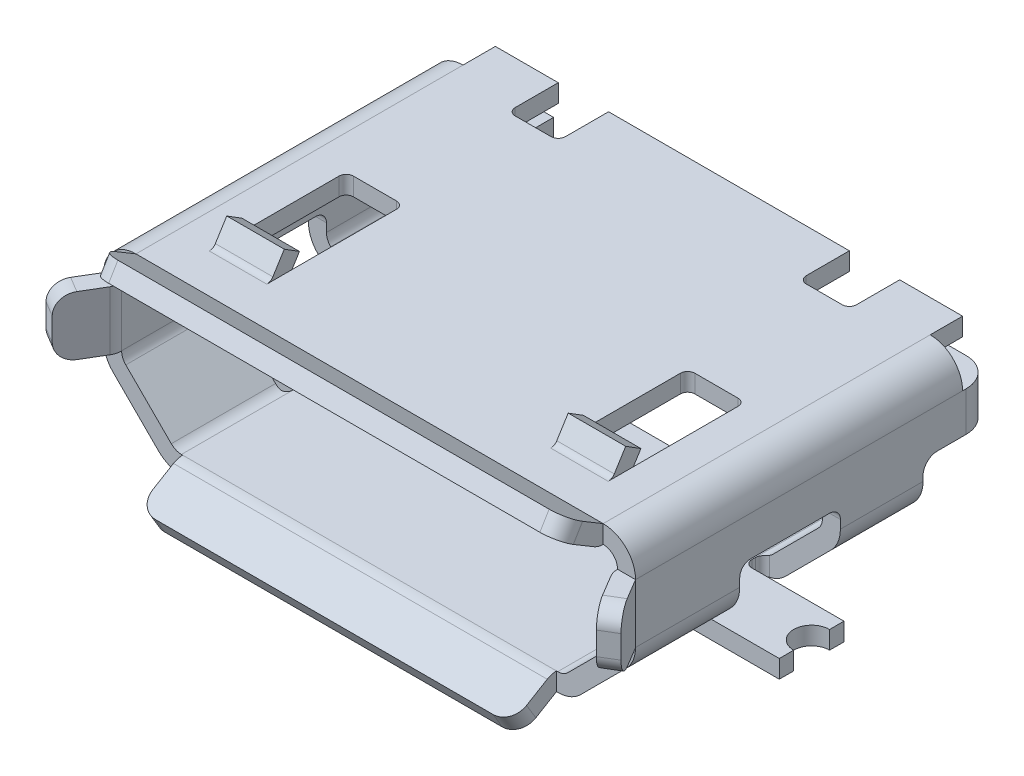
from build123d import *

# Parameters (mm, degrees)
EXTRUDE_THIN1_DEPTH     = 5
BOSS_EXTRUDE1_DEPTH     = 0.82
BOSS_EXTRUDE2_DEPTH     = 2.6
BOSS_EXTRUDE3_DEPTH     = 3.25
FILLET1_R               = 0.25
CUT_EXTRUDE1_DEPTH      = 1.1
CUT_EXTRUDE1_DEPTH_BACK = 1.55
FILLET2_R               = 0.15
BOSS_EXTRUDE4_DEPTH     = 0.25
FILLET3_R               = 0.1
CUT_EXTRUDE2_DEPTH      = 0.25
BOSS_EXTRUDE5_DEPTH     = 0.8
FILLET4_R               = 0.1
CUT_EXTRUDE3_DEPTH      = 5
CUT_EXTRUDE3_DEPTH_BACK = 5
SKETCH11_W              = 0.45
SKETCH11_H              = 0.45
CUT_EXTRUDE4_DEPTH      = 1.3
CUT_EXTRUDE4_DEPTH_BACK = 3.65
CUT_EXTRUDE5_DEPTH      = 0.8
FILLET5_R               = 0.1
CUT_EXTRUDE6_DEPTH      = 0.8
BOSS_EXTRUDE6_DEPTH     = 0.55


with BuildPart() as part:
    # Sketch1 → Extrude-Thin1 (new body)
    with BuildSketch(Plane.XY):
        with BuildLine():
            Line((3.25, 2.1), (-3.25, 2.1))
            ThreePointArc((-3.25, 2.1), (-3.568198052, 1.968198052), (-3.7, 1.65))
            Line((-3.7, 1.65), (-3.7, 0.832842712))
            ThreePointArc((-3.7, 0.832842712), (-3.66574579, 0.660635168), (-3.568198052, 0.514644661))
            Line((-3.568198052, 0.514644661), (-2.935355339, -0.118198052))
            ThreePointArc((-2.935355339, -0.118198052), (-2.789364832, -0.21574579), (-2.617157288, -0.25))
            Line((-2.617157288, -0.25), (0, -0.25))
            Line((0, -0.25), (2.617157288, -0.25))
            ThreePointArc((2.617157288, -0.25), (2.789364832, -0.21574579), (2.935355339, -0.118198052))
            Line((2.935355339, -0.118198052), (3.568198052, 0.514644661))
            ThreePointArc((3.568198052, 0.514644661), (3.66574579, 0.660635168), (3.7, 0.832842712))
            Line((3.7, 0.832842712), (3.7, 1.65))
            ThreePointArc((3.7, 1.65), (3.568198052, 1.968198052), (3.25, 2.1))
        make_face()
        with BuildLine():
            Line((3.25, 1.85), (-3.25, 1.85))
            ThreePointArc((-3.25, 1.85), (-3.391421356, 1.791421356), (-3.45, 1.65))
            Line((-3.45, 1.65), (-3.45, 0.832842712))
            ThreePointArc((-3.45, 0.832842712), (-3.434775907, 0.756306026), (-3.391421356, 0.691421356))
            Line((-3.391421356, 0.691421356), (-2.758578644, 0.058578644))
            ThreePointArc((-2.758578644, 0.058578644), (-2.693693974, 0.015224093), (-2.617157288, 0))
            Line((-2.617157288, 0), (0, 0))
            Line((0, 0), (2.617157288, 0))
            ThreePointArc((2.617157288, 0), (2.693693974, 0.015224093), (2.758578644, 0.058578644))
            Line((2.758578644, 0.058578644), (3.391421356, 0.691421356))
            ThreePointArc((3.391421356, 0.691421356), (3.434775907, 0.756306026), (3.45, 0.832842712))
            Line((3.45, 0.832842712), (3.45, 1.65))
            ThreePointArc((3.45, 1.65), (3.391421356, 1.791421356), (3.25, 1.85))
        make_face(mode=Mode.SUBTRACT)
    extrude(amount=-EXTRUDE_THIN1_DEPTH)

    # Sketch2 → Boss-Extrude1 (add)
    with BuildSketch(Plane(origin=(0, 1.65, 0), x_dir=(1, 0, 0), z_dir=(0, 1, 0))):
        with BuildLine():
            Line((-3.7, 0), (-4, -0.501696258))
            Line((-4, -0.501696258), (-3.785434976, -0.63))
            Line((-3.785434976, -0.63), (-3.485434976, -0.128303742))
            ThreePointArc((-3.485434976, -0.128303742), (-3.45902152, -0.066553527), (-3.45, 0))
            Line((-3.45, 0), (-3.7, 0))
        make_face()
        with BuildLine():
            Line((3.7, 0), (4, -0.501696258))
            Line((4, -0.501696258), (3.785434976, -0.63))
            Line((3.785434976, -0.63), (3.485434976, -0.128303742))
            ThreePointArc((3.485434976, -0.128303742), (3.45902152, -0.066553527), (3.45, 0))
            Line((3.45, 0), (3.7, 0))
        make_face()
    extrude(amount=-BOSS_EXTRUDE1_DEPTH)

    # Sketch4 → Boss-Extrude2 (add, symmetric)
    with BuildSketch(Plane(origin=(0, 0, 0), x_dir=(0, 0, -1), z_dir=(1, 0, 0))):
        with BuildLine():
            Line((0, -0.25), (-0.501696258, -0.55))
            Line((-0.501696258, -0.55), (-0.63, -0.335434976))
            Line((-0.63, -0.335434976), (-0.128303742, -0.035434976))
            ThreePointArc((-0.128303742, -0.035434976), (-0.066553527, -0.00902152), (0, 0))
            Line((0, 0), (0, -0.25))
        make_face()
    extrude(amount=BOSS_EXTRUDE2_DEPTH, both=True)

    # Sketch3 → Boss-Extrude3 (add, symmetric)
    with BuildSketch(Plane(origin=(0, 0, 0), x_dir=(0, 0, -1), z_dir=(1, 0, 0))):
        with BuildLine():
            Line((0, 2.1), (-0.501696258, 2.4))
            Line((-0.501696258, 2.4), (-0.63, 2.185434976))
            Line((-0.63, 2.185434976), (-0.128303742, 1.885434976))
            ThreePointArc((-0.128303742, 1.885434976), (-0.066553527, 1.85902152), (0, 1.85))
            Line((0, 1.85), (0, 2.1))
        make_face()
    extrude(amount=BOSS_EXTRUDE3_DEPTH, both=True)

    # Fillet1
    fillet1_edges = [part.edges().sort_by_distance(p)[0] for p in [
        (3.892717488, 0.83, 0.565848129),
        (3.892717488, 1.65, 0.565848129),
        (-3.892717488, 0.83, 0.565848129),
        (-3.892717488, 1.65, 0.565848129),
        (-2.6, -0.442717488, 0.565848129),
        (2.6, -0.442717488, 0.565848129),
        (3.25, 2.292717488, 0.565848129),
        (-3.25, 2.292717488, 0.565848129),
    ]]
    fillet(fillet1_edges, radius=FILLET1_R)

    # Sketch5 → Cut-Extrude1 (cut, two sides)
    with BuildSketch(Plane(origin=(0, 0, 0), x_dir=(1, 0, 0), z_dir=(0, 1, 0))) as cut_extrude1_sk:
        with BuildLine():
            Line((2.717157288, 1.45), (3.7, 1.45))
            Line((3.7, 1.45), (3.7, 2.85))
            Line((3.7, 2.85), (2.717157288, 2.85))
            ThreePointArc((2.717157288, 2.85), (2.646446609, 2.820710678), (2.617157288, 2.75))
            Line((2.617157288, 2.75), (2.617157288, 1.55))
            ThreePointArc((2.617157288, 1.55), (2.646446609, 1.479289322), (2.717157288, 1.45))
        make_face()
        with BuildLine():
            Line((-3.7, 2.85), (-2.717157288, 2.85))
            ThreePointArc((-2.717157288, 2.85), (-2.646446609, 2.820710678), (-2.617157288, 2.75))
            Line((-2.617157288, 2.75), (-2.617157288, 1.55))
            ThreePointArc((-2.617157288, 1.55), (-2.646446609, 1.479289322), (-2.717157288, 1.45))
            Line((-2.717157288, 1.45), (-3.7, 1.45))
            Line((-3.7, 1.45), (-3.7, 2.85))
        make_face()
    extrude(amount=CUT_EXTRUDE1_DEPTH, mode=Mode.SUBTRACT)
    extrude(cut_extrude1_sk.sketch, amount=-CUT_EXTRUDE1_DEPTH_BACK, mode=Mode.SUBTRACT)

    # Fillet2
    fillet2_edges = [part.edges().sort_by_distance(p)[0] for p in [
        (3.575, 1.1, -2.85),
        (3.575, 1.1, -1.45),
        (-3.575, 1.1, -2.85),
        (-3.575, 1.1, -1.45),
    ]]
    fillet(fillet2_edges, radius=FILLET2_R)

    # Sketch6 → Boss-Extrude4 (add)
    with BuildSketch(Plane.XZ.offset(0.25)):
        with BuildLine():
            Line((-4, -1.7), (4, -1.7))
            Line((4, -1.7), (4, -1.9))
            ThreePointArc((4, -1.9), (3.75, -2.15), (4, -2.4))
            Line((4, -2.4), (4, -2.6))
            Line((4, -2.6), (-4, -2.6))
            Line((-4, -2.6), (-4, -2.4))
            ThreePointArc((-4, -2.4), (-3.75, -2.15), (-4, -1.9))
            Line((-4, -1.9), (-4, -1.7))
        make_face()
    extrude(amount=-BOSS_EXTRUDE4_DEPTH)

    # Fillet3
    fillet3_edges = [part.edges().sort_by_distance(p)[0] for p in [
        (-2.617157288, -0.125, -2.6),
        (-2.617157288, -0.125, -1.7),
        (2.617157288, -0.125, -1.7),
        (2.617157288, -0.125, -2.6),
    ]]
    fillet(fillet3_edges, radius=FILLET3_R)

    # Sketch7 → Cut-Extrude2 (cut)
    with BuildSketch(Plane(origin=(0, 2.1, 0), x_dir=(1, 0, 0), z_dir=(0, 1, 0))):
        with BuildLine():
            Line((-2.675, 2.45), (-2.075, 2.45))
            ThreePointArc((-2.075, 2.45), (-2.004289322, 2.420710678), (-1.975, 2.35))
            Line((-1.975, 2.35), (-1.975, 0.6))
            Line((-1.975, 0.6), (-2.775, 0.6))
            Line((-2.775, 0.6), (-2.775, 2.35))
            ThreePointArc((-2.775, 2.35), (-2.745710678, 2.420710678), (-2.675, 2.45))
        make_face()
        with BuildLine():
            Line((2.075, 2.45), (2.675, 2.45))
            ThreePointArc((2.675, 2.45), (2.745710678, 2.420710678), (2.775, 2.35))
            Line((2.775, 2.35), (2.775, 0.6))
            Line((2.775, 0.6), (1.975, 0.6))
            Line((1.975, 0.6), (1.975, 2.35))
            ThreePointArc((1.975, 2.35), (2.004289322, 2.420710678), (2.075, 2.45))
        make_face()
    extrude(amount=-CUT_EXTRUDE2_DEPTH, mode=Mode.SUBTRACT)

    # Sketch9 → Boss-Extrude5 (add)
    with BuildSketch(Plane.ZY.offset(1.975)):
        with BuildLine():
            Line((-0.6, 2.1), (-0.788233436, 2.4))
            Line((-0.788233436, 2.4), (-1, 2.267128173))
            Line((-1, 2.267128173), (-0.811766564, 1.967128173))
            ThreePointArc((-0.811766564, 1.967128173), (-0.72100009, 1.88123305), (-0.6, 1.85))
            Line((-0.6, 1.85), (-0.6, 2.1))
        make_face()
    boss_extrude5 = extrude(amount=BOSS_EXTRUDE5_DEPTH)

    # Mirror1: Boss-Extrude5 across plane
    add(boss_extrude5.mirror(Plane(origin=(0, 0, 0), x_dir=(0, 0, 1), z_dir=(1, 0, 0))))

    # Fillet4
    fillet4_edges = [part.edges().sort_by_distance(p)[0] for p in [
        (-2.375, 2.1, -0.6),
        (2.375, 2.1, -0.6),
    ]]
    fillet(fillet4_edges, radius=FILLET4_R)

    # Sketch10 → Cut-Extrude3 (cut, two sides)
    with BuildSketch(Plane(origin=(0, 0, 0), x_dir=(0, 0, -1), z_dir=(1, 0, 0))) as cut_extrude3_sk:
        with BuildLine():
            Line((4, -0.25), (5, -0.25))
            Line((5, -0.25), (5, 1.1))
            Line((5, 1.1), (4.2, 1.1))
            ThreePointArc((4.2, 1.1), (4.058578644, 1.041421356), (4, 0.9))
            Line((4, 0.9), (4, -0.25))
        make_face()
    extrude(amount=CUT_EXTRUDE3_DEPTH, mode=Mode.SUBTRACT)
    extrude(cut_extrude3_sk.sketch, amount=-CUT_EXTRUDE3_DEPTH_BACK, mode=Mode.SUBTRACT)

    # Sketch11 → Cut-Extrude4 (cut, two sides)
    with BuildSketch(Plane(origin=(0, 2.1, 0), x_dir=(1, 0, 0), z_dir=(0, 1, 0))) as cut_extrude4_sk:
        with Locations((-3.475, 4.775)):
            Rectangle(SKETCH11_W, SKETCH11_H)
        with Locations((3.475, 4.775)):
            Rectangle(SKETCH11_W, SKETCH11_H)
    extrude(amount=CUT_EXTRUDE4_DEPTH, mode=Mode.SUBTRACT)
    extrude(cut_extrude4_sk.sketch, amount=-CUT_EXTRUDE4_DEPTH_BACK, mode=Mode.SUBTRACT)

    # Sketch12 → Cut-Extrude5 (cut)
    with BuildSketch(Plane.XZ.offset(0.25)):
        with BuildLine():
            Line((-2.05, -3.5), (2.05, -3.5))
            ThreePointArc((2.05, -3.5), (2.191421356, -3.558578644), (2.25, -3.7))
            Line((2.25, -3.7), (2.25, -4))
            Line((2.25, -4), (-2.25, -4))
            Line((-2.25, -4), (-2.25, -3.7))
            ThreePointArc((-2.25, -3.7), (-2.191421356, -3.558578644), (-2.05, -3.5))
        make_face()
    extrude(amount=-CUT_EXTRUDE5_DEPTH, mode=Mode.SUBTRACT)

    # Fillet5
    fillet5_edges = [part.edges().sort_by_distance(p)[0] for p in [
        (-2.25, -0.125, -4),
        (2.25, -0.125, -4),
    ]]
    fillet(fillet5_edges, radius=FILLET5_R)

    # Sketch13 → Cut-Extrude6 (cut)
    with BuildSketch(Plane(origin=(0, 2.1, 0), x_dir=(1, 0, 0), z_dir=(0, 1, 0))):
        with BuildLine():
            Line((-2.375, 5), (-1.675, 5))
            Line((-1.675, 5), (-1.675, 4.4))
            ThreePointArc((-1.675, 4.4), (-1.704289322, 4.329289322), (-1.775, 4.3))
            Line((-1.775, 4.3), (-2.275, 4.3))
            ThreePointArc((-2.275, 4.3), (-2.345710678, 4.329289322), (-2.375, 4.4))
            Line((-2.375, 4.4), (-2.375, 5))
        make_face()
        with BuildLine():
            Line((1.675, 5), (2.375, 5))
            Line((2.375, 5), (2.375, 4.4))
            ThreePointArc((2.375, 4.4), (2.345710678, 4.329289322), (2.275, 4.3))
            Line((2.275, 4.3), (1.775, 4.3))
            ThreePointArc((1.775, 4.3), (1.704289322, 4.329289322), (1.675, 4.4))
            Line((1.675, 4.4), (1.675, 5))
        make_face()
    extrude(amount=-CUT_EXTRUDE6_DEPTH, mode=Mode.SUBTRACT)

    # Sketch14 → Boss-Extrude6 (add)
    with BuildSketch(Plane(origin=(0, 1.65, 0), x_dir=(1, 0, 0), z_dir=(0, 1, 0))):
        with BuildLine():
            Line((-3.7, 4.55), (-3.7, 4.6))
            ThreePointArc((-3.7, 4.6), (-3.582842712, 4.882842712), (-3.3, 5))
            Line((-3.3, 5), (-2.44, 5))
            Line((-2.44, 5), (-2.44, 4.75))
            Line((-2.44, 4.75), (-3.3, 4.75))
            ThreePointArc((-3.3, 4.75), (-3.406066017, 4.706066017), (-3.45, 4.6))
            Line((-3.45, 4.6), (-3.45, 4.55))
            Line((-3.45, 4.55), (-3.7, 4.55))
        make_face()
    boss_extrude6 = extrude(amount=-BOSS_EXTRUDE6_DEPTH)

    # Mirror2: Boss-Extrude6 across plane
    add(boss_extrude6.mirror(Plane(origin=(0, 0, 0), x_dir=(0, 0, 1), z_dir=(1, 0, 0))))


solid = part.part
